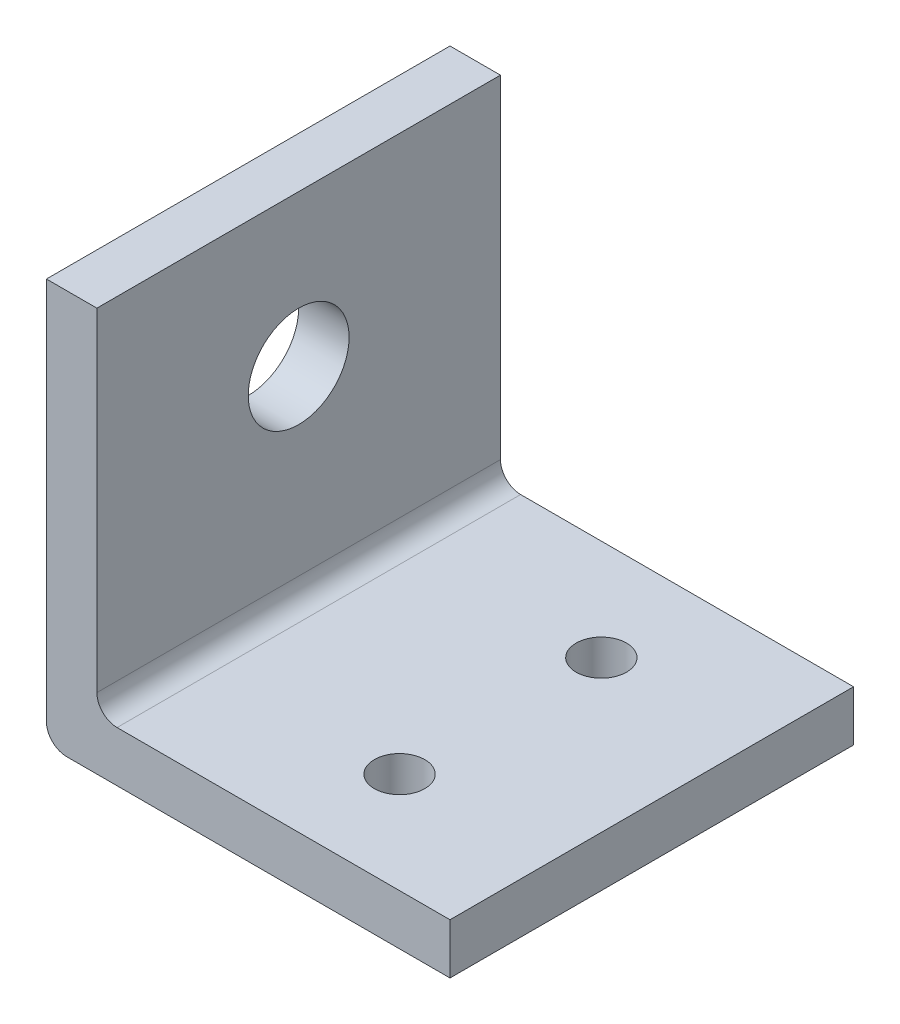
from build123d import *

# Parameters (mm, degrees)
BOSS_EXTRUDE1_DEPTH = 40
SKETCH3_R           = 5
CUT_EXTRUDE1_DEPTH  = 40
SKETCH4_R           = 2.5
CUT_EXTRUDE2_DEPTH  = 40


with BuildPart() as part:
    # Sketch2 → Boss-Extrude1 (new body)
    with BuildSketch(Plane.XY):
        with BuildLine():
            Line((0, 2), (0, 40))
            Line((0, 40), (5, 40))
            Line((5, 40), (5, 7))
            ThreePointArc((5, 7), (5.585786438, 5.585786438), (7, 5))
            Line((7, 5), (40, 5))
            Line((40, 5), (40, 0))
            Line((40, 0), (2, 0))
            ThreePointArc((2, 0), (0.585786438, 0.585786438), (0, 2))
        make_face()
    extrude(amount=BOSS_EXTRUDE1_DEPTH)

    # Sketch3 → Cut-Extrude1 (cut)
    with BuildSketch(Plane(origin=(5, 0, 0), x_dir=(0, 0, -1), z_dir=(1, 0, 0))):
        with Locations((-20, 25)):
            Circle(SKETCH3_R)
    extrude(amount=-CUT_EXTRUDE1_DEPTH, mode=Mode.SUBTRACT)

    # Sketch4 → Cut-Extrude2 (cut)
    with BuildSketch(Plane(origin=(0, 5, 0), x_dir=(1, 0, 0), z_dir=(0, 1, 0))):
        with Locations((25, -10)):
            Circle(SKETCH4_R)
        with Locations((25, -30)):
            Circle(SKETCH4_R)
    extrude(amount=-CUT_EXTRUDE2_DEPTH, mode=Mode.SUBTRACT)


solid = part.part
